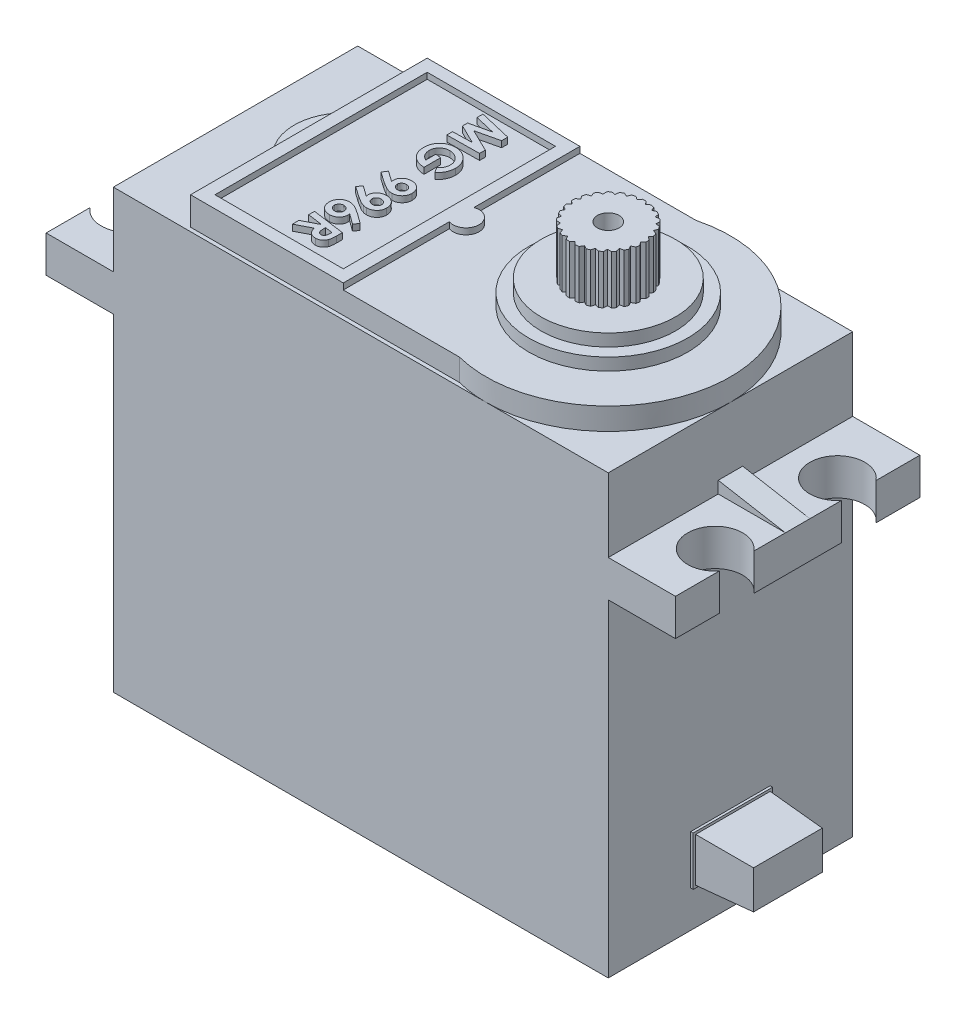
from build123d import *

# Parameters (mm, degrees)
ESQUISSE2_W             = 40.5
ESQUISSE2_H             = 20
BOSS_EXTRU_1_DEPTH      = 36.8
CHANFREIN1_SIZE         = 1
ESQUISSE3_W             = 6.5
ESQUISSE3_H             = 4
BOSS_EXTRU_2_DEPTH      = 0.2
ESQUISSE4_W             = 6.1
ESQUISSE4_H             = 3.6
BOSS_EXTRU_3_DEPTH      = 4.5
BOSS_EXTRU_3_TAPER      = 3
ESQUISSE5_W             = 5.5
ESQUISSE5_H             = 20
BOSS_EXTRU_4_DEPTH      = 3
BOSS_EXTRU_5_DEPTH      = 1.8
ESQUISSE8_W             = 12.5
ESQUISSE8_H             = 19.364916732
ESQUISSE8_W_2           = 10.5
ESQUISSE8_H_2           = 17.364916732
BOSS_EXTRU_6_DEPTH      = 0.5
NERVURE1_REACH          = 63.195
ESQUISSE6_WALL_W        = 129.97512572
ESQUISSE6_WALL_H        = 2
ESQUISSE9_R             = 2.25
ENL_V_MAT_EXTRU_1_DEPTH = 3
ESQUISSE10_R            = 1.069362743
BOSS_EXTRU_7_DEPTH      = 0.5
ESQUISSE11_R            = 6.5
BOSS_EXTRU_8_DEPTH      = 1
ESQUISSE12_R            = 5.5
BOSS_EXTRU_9_DEPTH      = 1
ESQUISSE13_R            = 3
BOSS_EXTRU_10_DEPTH     = 4
ENL_V_MAT_EXTRU_2_DEPTH = 4
TROU_TARAUD_2_561_D     = 1.778
TROU_TARAUD_2_561_DEPTH = 6.64
TROU_TARAUD_2_561_TIP   = 0.53416509
ENL_V_MAT_EXTRU_3_DEPTH = 0.5


with BuildPart() as part:
    # Esquisse2 → Boss.-Extru.1 (new body)
    with BuildSketch(Plane(origin=(0, 0, 0), x_dir=(1, 0, 0), z_dir=(0, 1, 0))):
        with Locations((20.25, 10)):
            Rectangle(ESQUISSE2_W, ESQUISSE2_H)
    extrude(amount=BOSS_EXTRU_1_DEPTH)

    # Chanfrein1
    chanfrein1_edges = [part.edges().sort_by_distance(p)[0] for p in [
        (20.25, 0, -20),
        (40.5, 0, -10),
        (20.25, 0, 0),
        (0, 0, -10),
    ]]
    chamfer(chanfrein1_edges, length=CHANFREIN1_SIZE)

    # Esquisse3 → Boss.-Extru.2 (add)
    with BuildSketch(Plane(origin=(40.5, 0, 0), x_dir=(0, 0, -1), z_dir=(1, 0, 0))):
        with Locations((10, 6)):
            Rectangle(ESQUISSE3_W, ESQUISSE3_H)
    extrude(amount=BOSS_EXTRU_2_DEPTH)

    # Esquisse4 → Boss.-Extru.3 (add)
    with BuildSketch(Plane(origin=(40.7, 0, 0), x_dir=(0, 0, -1), z_dir=(1, 0, 0))):
        with Locations((10, 6)):
            Rectangle(ESQUISSE4_W, ESQUISSE4_H)
    extrude(amount=BOSS_EXTRU_3_DEPTH, taper=BOSS_EXTRU_3_TAPER)

    # Esquisse5 → Boss.-Extru.4 (add)
    with BuildSketch(Plane(origin=(0, 30.8, 0), x_dir=(1, 0, 0), z_dir=(0, 1, 0))):
        with Locations((43.25, 10)):
            Rectangle(ESQUISSE5_W, ESQUISSE5_H)
        with Locations((-2.75, 10)):
            Rectangle(ESQUISSE5_W, ESQUISSE5_H)
    extrude(amount=-BOSS_EXTRU_4_DEPTH)

    # Esquisse7 → Boss.-Extru.5 (add)
    with BuildSketch(Plane(origin=(0, 36.8, 0), x_dir=(1, 0, 0), z_dir=(0, 1, 0))):
        with BuildLine():
            Line((28, 19.682458366), (6, 19.682458366))
            Line((6, 19.682458366), (6, 12.939387691))
            ThreePointArc((6, 12.939387691), (4.8, 10), (6, 7.060612309))
            Line((6, 7.060612309), (6, 0.317541634))
            Line((6, 0.317541634), (28, 0.317541634))
            ThreePointArc((28, 0.317541634), (40.5, 10), (28, 19.682458366))
        make_face()
    extrude(amount=BOSS_EXTRU_5_DEPTH)

    # Esquisse8 → Boss.-Extru.6 (add)
    with BuildSketch(Plane(origin=(0, 38.6, 0), x_dir=(1, 0, 0), z_dir=(0, 1, 0))):
        with Locations((12.25, 10)):
            Rectangle(ESQUISSE8_W, ESQUISSE8_H)
        with Locations((12.25, 10)):
            Rectangle(ESQUISSE8_W_2, ESQUISSE8_H_2, mode=Mode.SUBTRACT)
    extrude(amount=BOSS_EXTRU_6_DEPTH)

    # Esquisse6 wall → Nervure1 (add, up to next)
    with BuildSketch(Plane(origin=(43.25, 31.28654897, -10), x_dir=(-0.98470656344, 0.17422107771, 0), z_dir=(0.17422107771, 0.98470656344, 0)), mode=Mode.PRIVATE) as nervure1_sk1:
        Rectangle(ESQUISSE6_WALL_W, ESQUISSE6_WALL_H)
    nervure1_tool1 = extrude(nervure1_sk1.sketch, amount=-NERVURE1_REACH, mode=Mode.PRIVATE) - part.part
    nervure1 = nervure1_tool1.solids().sort_by_distance((43.25, 31.28654897, -10))[0]
    add(nervure1)

    # Symétrie1: Nervure1 across plane
    add(nervure1.mirror(Plane.ZY.offset(-20.25)))

    # Esquisse9 → Enlèv. mat.-Extru.1 (cut)
    with BuildSketch(Plane(origin=(0, 30.8, 0), x_dir=(1, 0, 0), z_dir=(0, 1, 0))):
        with Locations((-3.75, 15)):
            Circle(ESQUISSE9_R)
        with Locations((-3.75, 5)):
            Circle(ESQUISSE9_R)
        with Locations((44.25, 15)):
            Circle(ESQUISSE9_R)
        with Locations((44.25, 5)):
            Circle(ESQUISSE9_R)
    extrude(amount=-ENL_V_MAT_EXTRU_1_DEPTH, mode=Mode.SUBTRACT)

    # Esquisse10 → Boss.-Extru.7 (add)
    with BuildSketch(Plane(origin=(0, 38.6, 0), x_dir=(1, 0, 0), z_dir=(0, 1, 0))):
        with Locations((18.863979038, 10)):
            Circle(ESQUISSE10_R)
        Polygon((14.895833333, 17.378864517), (14.895833333, 16.873760517), (13.052442241, 16.444978632), (14.895833333, 15.539713542), (14.895833333, 15.071180556), (12.25, 15.037259615), (12.25, 15.512152778), (13.832623865, 15.546073718), (12.25, 16.323075254), (12.25, 16.737016727), (13.912126068, 17.123397436), (12.25, 17.514018263), (12.25, 18.000571748), align=None)
        with BuildLine():
            Line((14.413519965, 11.893212473), (14.14957265, 12.314574152))
            add(Edge.make_bspline(
                [(14.14957265, 12.314574152), (14.182226607, 12.344452028), (14.244607538, 12.401529634), (14.325928731, 12.491063998), (14.391922335, 12.578848082), (14.441898984, 12.667154377), (14.478787705, 12.757700404), (14.503895804, 12.852666333), (14.519754731, 12.95306459), (14.521705169, 13.021906131), (14.522702991, 13.057124733)],
                knots=[0, 0, 0, 0, 1.232885797, 2.355260147, 3.365556625, 4.287066597, 5.174814994, 6.082477048, 7.019015608, 8, 8, 8, 8], degree=3))
            add(Edge.make_bspline(
                [(14.522702991, 13.057124733), (14.521686925, 13.095364384), (14.519689994, 13.170518887), (14.500873636, 13.280150935), (14.471871138, 13.384693694), (14.430547824, 13.483730957), (14.37602753, 13.576738756), (14.310603553, 13.664500855), (14.233259477, 13.746911503), (14.174343486, 13.795530523), (14.144272503, 13.820345887)],
                knots=[0, 0, 0, 0, 1.037071857, 2.038214738, 3.009729149, 3.976855325, 4.941565424, 5.928389831, 6.942640983, 8, 8, 8, 8], degree=3))
            add(Edge.make_bspline(
                [(14.144272503, 13.820345887), (14.119098074, 13.838925772), (14.069293607, 13.875683755), (13.990748516, 13.923561019), (13.909783045, 13.96314346), (13.827256952, 13.9966325), (13.742303924, 14.021687181), (13.655425835, 14.040764914), (13.566285141, 14.051240002), (13.506159608, 14.052778618), (13.475923978, 14.05355235)],
                knots=[0, 0, 0, 0, 1.040839251, 2.059170575, 3.055630366, 4.037062373, 5.019110465, 5.999220985, 6.993858158, 8, 8, 8, 8], degree=3))
            add(Edge.make_bspline(
                [(13.475923978, 14.05355235), (13.446389285, 14.052838649), (13.388165025, 14.051431667), (13.302693434, 14.040347229), (13.221068283, 14.020814449), (13.142669436, 13.995202178), (13.068207437, 13.960903979), (12.997347209, 13.919389191), (12.930280706, 13.870317718), (12.86756691, 13.81430086), (12.810308914, 13.753008656), (12.76012294, 13.687570953), (12.717880889, 13.618626076), (12.683290563, 13.546146381), (12.656064777, 13.470176978), (12.637183746, 13.390531597), (12.625034783, 13.307666938), (12.623771226, 13.251153353), (12.623130342, 13.222489316)],
                knots=[0, 0, 0, 0, 1.066897471, 2.103265977, 3.106535126, 4.095591644, 5.078159493, 6.062322472, 7.058152725, 8.075375883, 9.096057735, 10.084186963, 11.049730852, 12.011871914, 12.980953841, 13.959387168, 14.96498868, 16, 16, 16, 16], degree=3))
            add(Edge.make_bspline(
                [(12.623130342, 13.222489316), (12.62352997, 13.200919765), (12.624321167, 13.158215716), (12.630867198, 13.094984655), (12.641499585, 13.033188568), (12.656192684, 12.972909638), (12.675512208, 12.914154242), (12.698930203, 12.856798498), (12.726293103, 12.80068424), (12.758406832, 12.746436633), (12.794238655, 12.693968773), (12.834685352, 12.644022395), (12.879496236, 12.596709454), (12.928435307, 12.551650676), (12.98124162, 12.508551759), (13.039018432, 12.46894969), (13.100490782, 12.431075996), (13.143816269, 12.408311625), (13.165865385, 12.396726429)],
                knots=[0, 0, 0, 0, 0.990751711, 1.961520103, 2.916931976, 3.869720035, 4.809138875, 5.755683625, 6.713987145, 7.674487982, 8.649319602, 9.630449541, 10.623757948, 11.640402946, 12.684918653, 13.752145235, 14.856026455, 16, 16, 16, 16], degree=3))
            Line((13.165865385, 12.396726429), (13.165865385, 13.232029581))
            Line((13.165865385, 13.232029581), (13.606837607, 13.171607906))
            Line((13.606837607, 13.171607906), (13.606837607, 11.814770299))
            add(Edge.make_bspline(
                [(13.606837607, 11.814770299), (13.553576953, 11.818164211), (13.449423544, 11.824801144), (13.297763777, 11.848819667), (13.154737828, 11.884392058), (13.019794624, 11.930502134), (12.893185857, 11.987615425), (12.775254695, 12.056619555), (12.665557739, 12.136162474), (12.565533037, 12.226966773), (12.475782242, 12.326397844), (12.396489875, 12.432596793), (12.330718138, 12.54636996), (12.276386727, 12.666200695), (12.233654404, 12.792560622), (12.203696237, 12.925771009), (12.185230178, 13.065613979), (12.183194733, 13.161126321), (12.18215812, 13.209768964)],
                knots=[0, 0, 0, 0, 1.148955532, 2.246830018, 3.301660101, 4.319666133, 5.314146826, 6.287838685, 7.257462643, 8.227280698, 9.191724348, 10.138440807, 11.076252923, 12.016254752, 12.968042649, 13.943717582, 14.952773983, 16, 16, 16, 16], degree=3))
            add(Edge.make_bspline(
                [(12.18215812, 13.209768964), (12.182422747, 13.236454621), (12.182945535, 13.289173934), (12.188315617, 13.367019666), (12.197484811, 13.442677664), (12.209525355, 13.516102052), (12.224926848, 13.587610509), (12.243849953, 13.656857329), (12.266805344, 13.724078008), (12.293385572, 13.788833866), (12.322306691, 13.852052819), (12.356049468, 13.912245692), (12.392500992, 13.970865644), (12.432978605, 14.026931448), (12.476454014, 14.081266613), (12.523609892, 14.133053839), (12.574262899, 14.1827447), (12.610237054, 14.213807595), (12.628430489, 14.229517228)],
                knots=[0, 0, 0, 0, 1.111489437, 2.195822267, 3.24832009, 4.285186852, 5.294177098, 6.294000398, 7.273796753, 8.250936178, 9.209044775, 10.167605497, 11.123223585, 12.083111191, 13.046265838, 14.020518746, 14.998904505, 16, 16, 16, 16], degree=3))
            add(Edge.make_bspline(
                [(12.628430489, 14.229517228), (12.658588763, 14.253396792), (12.718466815, 14.300808715), (12.814947345, 14.361673055), (12.915566575, 14.413613317), (13.020838592, 14.455207788), (13.12995092, 14.488460722), (13.243503183, 14.511673433), (13.361266447, 14.525638713), (13.441258231, 14.527502148), (13.48175414, 14.528445513)],
                knots=[0, 0, 0, 0, 0.999328569, 1.984127054, 2.959716786, 3.938705326, 4.922250225, 5.921072174, 6.947541011, 8, 8, 8, 8], degree=3))
            add(Edge.make_bspline(
                [(13.48175414, 14.528445513), (13.53129847, 14.527173323), (13.629061566, 14.52466298), (13.77282981, 14.503175961), (13.911565339, 14.469386095), (14.045327899, 14.42159429), (14.173480699, 14.359024131), (14.296477058, 14.283156585), (14.414850664, 14.194334344), (14.525642072, 14.092177215), (14.628023605, 13.981364426), (14.717958358, 13.863705939), (14.793658228, 13.740327698), (14.856346862, 13.612238591), (14.904011351, 13.478215362), (14.938507887, 13.339436142), (14.959884545, 13.195238002), (14.962398803, 13.097302998), (14.963675214, 13.047584468)],
                knots=[0, 0, 0, 0, 1.022497491, 2.017637963, 2.994389496, 3.967079589, 4.944335062, 5.93346684, 6.946839843, 7.995112064, 9.040696054, 10.058471571, 11.04760335, 12.024858823, 12.997548916, 13.978718102, 14.973858573, 16, 16, 16, 16], degree=3))
            add(Edge.make_bspline(
                [(14.963675214, 13.047584468), (14.963073734, 13.010268263), (14.96187604, 12.935962555), (14.948764051, 12.825348338), (14.929734364, 12.715895027), (14.901241146, 12.608753554), (14.866779416, 12.50483789), (14.825069394, 12.405472052), (14.77709042, 12.311265198), (14.721760549, 12.221593179), (14.658650029, 12.135656527), (14.58655147, 12.051845362), (14.504433106, 11.970418038), (14.444260862, 11.919318362), (14.413519965, 11.893212473)],
                knots=[0, 0, 0, 0, 1.013985835, 2.019094276, 3.024340414, 4.032027573, 5.029903266, 5.998629461, 6.958804651, 7.901192451, 8.859925033, 9.854431412, 10.903868303, 12, 12, 12, 12], degree=3))
        make_face()
        with BuildLine():
            Line((12.18215812, 9.722272302), (12.428084936, 10.089572483))
            Line((12.428084936, 10.089572483), (13.292008881, 9.478465545))
            add(Edge.make_bspline(
                [(13.292008881, 9.478465545), (13.285044745, 9.507656953), (13.271936971, 9.562600513), (13.269003247, 9.618990213), (13.267628205, 9.645420172)],
                knots=[0, 0, 0, 0, 1.062596194, 2, 2, 2, 2], degree=3))
            add(Edge.make_bspline(
                [(13.267628205, 9.645420172), (13.268370326, 9.669484416), (13.269834611, 9.716965777), (13.280592147, 9.786868361), (13.298781282, 9.853969752), (13.323754696, 9.91858972), (13.356185706, 9.980380058), (13.396602665, 10.038934361), (13.443356714, 10.095229716), (13.496534781, 10.148553985), (13.555489352, 10.196736567), (13.618316863, 10.239579909), (13.684811225, 10.275591006), (13.754446078, 10.305488754), (13.827595228, 10.328505371), (13.904383904, 10.343920384), (13.984439422, 10.354607871), (14.039116571, 10.355643708), (14.066890358, 10.356169872)],
                knots=[0, 0, 0, 0, 0.970086177, 1.914085144, 2.843757081, 3.768448548, 4.702069427, 5.650466095, 6.631863717, 7.649361026, 8.681859104, 9.697409525, 10.711084413, 11.725960042, 12.748829391, 13.796646255, 14.880785151, 16, 16, 16, 16], degree=3))
            add(Edge.make_bspline(
                [(14.066890358, 10.356169872), (14.098197844, 10.355518936), (14.159801729, 10.354238085), (14.250317834, 10.342276224), (14.336868289, 10.322673607), (14.419579012, 10.2957472), (14.497774244, 10.260469755), (14.572078653, 10.217814045), (14.642299223, 10.16708307), (14.708049837, 10.109288105), (14.76770795, 10.045249169), (14.820616324, 9.976906928), (14.864955402, 9.903596822), (14.900928581, 9.826020649), (14.929315065, 9.744194602), (14.949369106, 9.658239669), (14.961103379, 9.567831814), (14.962805317, 9.506237563), (14.963675214, 9.474755442)],
                knots=[0, 0, 0, 0, 1.067153374, 2.099842657, 3.106801845, 4.089832761, 5.060584944, 6.026765153, 7.006523203, 8.009636506, 9.007035051, 9.986663441, 10.951659663, 11.921944397, 12.897414564, 13.899858298, 14.926573288, 16, 16, 16, 16], degree=3))
            add(Edge.make_bspline(
                [(14.963675214, 9.474755442), (14.963051152, 9.446088804), (14.961824572, 9.389745137), (14.949549956, 9.307470148), (14.931272291, 9.228678737), (14.904666719, 9.153625098), (14.86994262, 9.082315393), (14.827840697, 9.014643187), (14.778218026, 8.950774394), (14.721695011, 8.891211855), (14.659741804, 8.837106924), (14.593764232, 8.789645513), (14.524432178, 8.749486789), (14.451309401, 8.717100659), (14.374775546, 8.691728494), (14.295030193, 8.672898961), (14.211692758, 8.66233727), (14.155078169, 8.660869964), (14.126252003, 8.660122863)],
                knots=[0, 0, 0, 0, 1.054249505, 2.072105013, 3.054563783, 4.027228313, 4.995537151, 5.967962625, 6.955035867, 7.966830736, 8.985184481, 9.977553814, 10.953342403, 11.928372592, 12.915253103, 13.916696589, 14.939254872, 16, 16, 16, 16], degree=3))
            add(Edge.make_bspline(
                [(14.126252003, 8.660122863), (14.102914166, 8.660489033), (14.056488057, 8.661217456), (13.987588394, 8.668329291), (13.919779494, 8.679961529), (13.875492157, 8.691107359), (13.853294438, 8.696693877)],
                knots=[0, 0, 0, 0, 1.013662365, 2.016484985, 3.005821674, 4, 4, 4, 4], degree=3))
            add(Edge.make_bspline(
                [(13.853294438, 8.696693877), (13.821887718, 8.706370116), (13.759147027, 8.725700181), (13.667547042, 8.761743499), (13.577671496, 8.801709608), (13.519749284, 8.832393511), (13.49076439, 8.847748064)],
                knots=[0, 0, 0, 0, 1.00191864, 2.001516544, 2.999937518, 4, 4, 4, 4], degree=3))
            add(Edge.make_bspline(
                [(13.49076439, 8.847748064), (13.441653178, 8.874830127), (13.345151324, 8.928045457), (13.205430961, 9.011901855), (13.071945365, 9.095963773), (12.986700987, 9.154861062), (12.944849259, 9.183777377)],
                knots=[0, 0, 0, 0, 1.049210121, 2.061662041, 3.048350216, 4, 4, 4, 4], degree=3))
            Line((12.944849259, 9.183777377), (12.18215812, 9.722272302))
        make_face()
        with BuildLine():
            add(Edge.make_bspline(
                [(13.708600427, 9.524576823), (13.709035217, 9.511479633), (13.709897329, 9.485510159), (13.715941075, 9.447349734), (13.725212391, 9.410397192), (13.739586639, 9.375402111), (13.75610301, 9.340901898), (13.778364906, 9.308978323), (13.803206007, 9.277666857), (13.832488349, 9.249102596), (13.863528526, 9.222008653), (13.897627985, 9.199422824), (13.932225857, 9.178769487), (13.969324504, 9.163200063), (14.007258901, 9.150034634), (14.047232721, 9.14207625), (14.088234294, 9.135580956), (14.116330443, 9.135205348), (14.130492121, 9.135016026)],
                knots=[0, 0, 0, 0, 0.985210318, 1.953502403, 2.901504212, 3.844552657, 4.795811415, 5.772915833, 6.765364857, 7.799414466, 8.846288802, 9.8603182, 10.872777757, 11.873031683, 12.88199396, 13.888500911, 14.935712839, 16, 16, 16, 16], degree=3))
            add(Edge.make_bspline(
                [(14.130492121, 9.135016026), (14.157143961, 9.13604922), (14.209147112, 9.138065192), (14.283241468, 9.159330417), (14.351318483, 9.191840168), (14.400879842, 9.230569974), (14.435944253, 9.266404387), (14.459417419, 9.294714951), (14.478648472, 9.325214323), (14.495268824, 9.356524442), (14.507446426, 9.390138865), (14.51644421, 9.424897614), (14.521948085, 9.461330131), (14.522448573, 9.486043361), (14.522702991, 9.498606103)],
                knots=[0, 0, 0, 0, 1.605710682, 3.133067493, 4.617246605, 6.139001981, 6.901113253, 7.644390981, 8.354770773, 9.075414747, 9.781050313, 10.508300066, 11.241708108, 12, 12, 12, 12], degree=3))
            add(Edge.make_bspline(
                [(14.522702991, 9.498606103), (14.522269913, 9.511877837), (14.521416852, 9.53801998), (14.515432771, 9.576394246), (14.505848066, 9.613140623), (14.492811368, 9.648395673), (14.474739767, 9.681484135), (14.453796485, 9.713340538), (14.428323669, 9.74334752), (14.399563232, 9.771525131), (14.368061273, 9.797369413), (14.334280593, 9.819814185), (14.298862501, 9.838986534), (14.261454941, 9.854239777), (14.222551458, 9.86677054), (14.181632759, 9.874880111), (14.138956083, 9.880581667), (14.109841649, 9.881041833), (14.094981136, 9.881276709)],
                knots=[0, 0, 0, 0, 0.99542305, 1.960745347, 2.905839599, 3.841219243, 4.772081027, 5.727802437, 6.696757192, 7.718306701, 8.745001724, 9.748509204, 10.756557466, 11.760764865, 12.775153388, 13.817469606, 14.885998626, 16, 16, 16, 16], degree=3))
            add(Edge.make_bspline(
                [(14.094981136, 9.881276709), (14.068706262, 9.880141045), (14.017537033, 9.877929387), (13.944133473, 9.858128398), (13.877187411, 9.826087871), (13.828333169, 9.788589095), (13.793554419, 9.754137239), (13.770977448, 9.726130977), (13.751346378, 9.69670676), (13.736291493, 9.665301665), (13.723777186, 9.632565508), (13.714818203, 9.598112565), (13.709359371, 9.561853625), (13.708856206, 9.537139845), (13.708600427, 9.524576823)],
                knots=[0, 0, 0, 0, 1.609136234, 3.133726194, 4.626556867, 6.135078296, 6.886042596, 7.625661421, 8.33802277, 9.050466543, 9.75695111, 10.485047691, 11.229887978, 12, 12, 12, 12], degree=3))
        make_face(mode=Mode.SUBTRACT)
        with BuildLine():
            Line((12.18215812, 7.653094952), (12.428084936, 8.020395132))
            Line((12.428084936, 8.020395132), (13.292008881, 7.409288194))
            add(Edge.make_bspline(
                [(13.292008881, 7.409288194), (13.285044745, 7.438479603), (13.271936971, 7.493423162), (13.269003247, 7.549812862), (13.267628205, 7.576242822)],
                knots=[0, 0, 0, 0, 1.062596194, 2, 2, 2, 2], degree=3))
            add(Edge.make_bspline(
                [(13.267628205, 7.576242822), (13.268370326, 7.600307066), (13.269834611, 7.647788427), (13.280592147, 7.717691011), (13.298781282, 7.784792402), (13.323754696, 7.84941237), (13.356185706, 7.911202708), (13.396602665, 7.96975701), (13.443356714, 8.026052366), (13.496534781, 8.079376634), (13.555489352, 8.127559217), (13.618316863, 8.170402559), (13.684811225, 8.206413656), (13.754446078, 8.236311403), (13.827595228, 8.259328021), (13.904383904, 8.274743034), (13.984439422, 8.285430521), (14.039116571, 8.286466358), (14.066890358, 8.286992521)],
                knots=[0, 0, 0, 0, 0.970086177, 1.914085144, 2.843757081, 3.768448548, 4.702069427, 5.650466095, 6.631863717, 7.649361026, 8.681859104, 9.697409525, 10.711084413, 11.725960042, 12.748829391, 13.796646255, 14.880785151, 16, 16, 16, 16], degree=3))
            add(Edge.make_bspline(
                [(14.066890358, 8.286992521), (14.098197844, 8.286341585), (14.159801729, 8.285060735), (14.250317834, 8.273098874), (14.336868289, 8.253496257), (14.419579012, 8.22656985), (14.497774244, 8.191292404), (14.572078653, 8.148636695), (14.642299223, 8.09790572), (14.708049837, 8.040110754), (14.76770795, 7.976071819), (14.820616324, 7.907729577), (14.864955402, 7.834419472), (14.900928581, 7.756843298), (14.929315065, 7.675017251), (14.949369106, 7.589062318), (14.961103379, 7.498654464), (14.962805317, 7.437060212), (14.963675214, 7.405578092)],
                knots=[0, 0, 0, 0, 1.067153374, 2.099842657, 3.106801845, 4.089832761, 5.060584944, 6.026765153, 7.006523203, 8.009636506, 9.007035051, 9.986663441, 10.951659663, 11.921944397, 12.897414564, 13.899858298, 14.926573288, 16, 16, 16, 16], degree=3))
            add(Edge.make_bspline(
                [(14.963675214, 7.405578092), (14.963051152, 7.376911454), (14.961824572, 7.320567786), (14.949549956, 7.238292797), (14.931272291, 7.159501386), (14.904666719, 7.084447748), (14.86994262, 7.013138043), (14.827840697, 6.945465836), (14.778218026, 6.881597044), (14.721695011, 6.822034504), (14.659741804, 6.767929574), (14.593764232, 6.720468163), (14.524432178, 6.680309439), (14.451309401, 6.647923309), (14.374775546, 6.622551144), (14.295030193, 6.60372161), (14.211692758, 6.593159919), (14.155078169, 6.591692613), (14.126252003, 6.590945513)],
                knots=[0, 0, 0, 0, 1.054249505, 2.072105013, 3.054563783, 4.027228313, 4.995537151, 5.967962625, 6.955035867, 7.966830736, 8.985184481, 9.977553814, 10.953342403, 11.928372592, 12.915253103, 13.916696589, 14.939254872, 16, 16, 16, 16], degree=3))
            add(Edge.make_bspline(
                [(14.126252003, 6.590945513), (14.102914166, 6.591311682), (14.056488057, 6.592040106), (13.987588394, 6.59915194), (13.919779494, 6.610784179), (13.875492157, 6.621930009), (13.853294438, 6.627516526)],
                knots=[0, 0, 0, 0, 1.013662365, 2.016484985, 3.005821674, 4, 4, 4, 4], degree=3))
            add(Edge.make_bspline(
                [(13.853294438, 6.627516526), (13.821887718, 6.637192765), (13.759147027, 6.65652283), (13.667547042, 6.692566149), (13.577671496, 6.732532258), (13.519749284, 6.76321616), (13.49076439, 6.778570713)],
                knots=[0, 0, 0, 0, 1.00191864, 2.001516544, 2.999937518, 4, 4, 4, 4], degree=3))
            add(Edge.make_bspline(
                [(13.49076439, 6.778570713), (13.441653178, 6.805652777), (13.345151324, 6.858868107), (13.205430961, 6.942724505), (13.071945365, 7.026786422), (12.986700987, 7.085683711), (12.944849259, 7.114600027)],
                knots=[0, 0, 0, 0, 1.049210121, 2.061662041, 3.048350216, 4, 4, 4, 4], degree=3))
            Line((12.944849259, 7.114600027), (12.18215812, 7.653094952))
        make_face()
        with BuildLine():
            add(Edge.make_bspline(
                [(13.708600427, 7.455399472), (13.709035217, 7.442302282), (13.709897329, 7.416332809), (13.715941075, 7.378172383), (13.725212391, 7.341219842), (13.739586639, 7.30622476), (13.75610301, 7.271724548), (13.778364906, 7.239800973), (13.803206007, 7.208489506), (13.832488349, 7.179925245), (13.863528526, 7.152831302), (13.897627985, 7.130245474), (13.932225857, 7.109592136), (13.969324504, 7.094022712), (14.007258901, 7.080857283), (14.047232721, 7.0728989), (14.088234294, 7.066403606), (14.116330443, 7.066027998), (14.130492121, 7.065838675)],
                knots=[0, 0, 0, 0, 0.985210318, 1.953502403, 2.901504212, 3.844552657, 4.795811415, 5.772915833, 6.765364857, 7.799414466, 8.846288802, 9.8603182, 10.872777757, 11.873031683, 12.88199396, 13.888500911, 14.935712839, 16, 16, 16, 16], degree=3))
            add(Edge.make_bspline(
                [(14.130492121, 7.065838675), (14.157143961, 7.06687187), (14.209147112, 7.068887842), (14.283241468, 7.090153067), (14.351318483, 7.122662817), (14.400879842, 7.161392623), (14.435944253, 7.197227037), (14.459417419, 7.225537601), (14.478648472, 7.256036972), (14.495268824, 7.287347092), (14.507446426, 7.320961514), (14.51644421, 7.355720264), (14.521948085, 7.392152781), (14.522448573, 7.416866011), (14.522702991, 7.429428753)],
                knots=[0, 0, 0, 0, 1.605710682, 3.133067493, 4.617246605, 6.139001981, 6.901113253, 7.644390981, 8.354770773, 9.075414747, 9.781050313, 10.508300066, 11.241708108, 12, 12, 12, 12], degree=3))
            add(Edge.make_bspline(
                [(14.522702991, 7.429428753), (14.522269913, 7.442700487), (14.521416852, 7.468842629), (14.515432771, 7.507216895), (14.505848066, 7.543963272), (14.492811368, 7.579218323), (14.474739767, 7.612306785), (14.453796485, 7.644163187), (14.428323669, 7.67417017), (14.399563232, 7.702347781), (14.368061273, 7.728192063), (14.334280593, 7.750636835), (14.298862501, 7.769809184), (14.261454941, 7.785062426), (14.222551458, 7.79759319), (14.181632759, 7.80570276), (14.138956083, 7.811404317), (14.109841649, 7.811864483), (14.094981136, 7.812099359)],
                knots=[0, 0, 0, 0, 0.99542305, 1.960745347, 2.905839599, 3.841219243, 4.772081027, 5.727802437, 6.696757192, 7.718306701, 8.745001724, 9.748509204, 10.756557466, 11.760764865, 12.775153388, 13.817469606, 14.885998626, 16, 16, 16, 16], degree=3))
            add(Edge.make_bspline(
                [(14.094981136, 7.812099359), (14.068706262, 7.810963695), (14.017537033, 7.808752037), (13.944133473, 7.788951048), (13.877187411, 7.756910521), (13.828333169, 7.719411745), (13.793554419, 7.684959889), (13.770977448, 7.656953627), (13.751346378, 7.62752941), (13.736291493, 7.596124314), (13.723777186, 7.563388158), (13.714818203, 7.528935214), (13.709359371, 7.492676275), (13.708856206, 7.467962495), (13.708600427, 7.455399472)],
                knots=[0, 0, 0, 0, 1.609136234, 3.133726194, 4.626556867, 6.135078296, 6.886042596, 7.625661421, 8.33802277, 9.050466543, 9.75695111, 10.485047691, 11.229887978, 12, 12, 12, 12], degree=3))
        make_face(mode=Mode.SUBTRACT)
        with BuildLine():
            Line((14.963675214, 5.230397803), (14.715628339, 4.856207432))
            Line((14.715628339, 4.856207432), (13.851704394, 5.485864884))
            add(Edge.make_bspline(
                [(13.851704394, 5.485864884), (13.855777165, 5.470715729), (13.863728117, 5.441141223), (13.872191365, 5.397426144), (13.877192941, 5.355775866), (13.877874367, 5.328816242), (13.878205128, 5.315730168)],
                knots=[0, 0, 0, 0, 1.089609887, 2.127159907, 3.090932268, 4, 4, 4, 4], degree=3))
            add(Edge.make_bspline(
                [(13.878205128, 5.315730168), (13.877455949, 5.291139017), (13.875977463, 5.242609027), (13.865343356, 5.171263743), (13.846877066, 5.102859399), (13.822428086, 5.036669894), (13.788610828, 4.97408479), (13.749721534, 4.913170376), (13.702436464, 4.855723128), (13.648843314, 4.801832949), (13.590345582, 4.752077921), (13.527647789, 4.708348257), (13.461160341, 4.671691674), (13.391289018, 4.641967567), (13.318202403, 4.618497671), (13.241588402, 4.601540225), (13.161376791, 4.591258551), (13.106710995, 4.590165347), (13.078942975, 4.589610043)],
                knots=[0, 0, 0, 0, 0.981715411, 1.937389526, 2.871580341, 3.806968751, 4.747211669, 5.7059007, 6.688578603, 7.711082162, 8.737083298, 9.750667409, 10.757800367, 11.76273248, 12.777714656, 13.818234204, 14.891750959, 16, 16, 16, 16], degree=3))
            add(Edge.make_bspline(
                [(13.078942975, 4.589610043), (13.047626205, 4.590195647), (12.985980854, 4.591348377), (12.89557458, 4.604250308), (12.808859798, 4.623457814), (12.726242983, 4.65115616), (12.64780308, 4.686971739), (12.573278252, 4.730507867), (12.503005379, 4.782469313), (12.437061226, 4.841306691), (12.37770705, 4.906732716), (12.325075182, 4.976555907), (12.280857948, 5.05122745), (12.244894792, 5.130388417), (12.216523098, 5.213799613), (12.19640816, 5.301504048), (12.18476632, 5.393682475), (12.183038507, 5.456504628), (12.18215812, 5.488514957)],
                knots=[0, 0, 0, 0, 1.056630681, 2.079919763, 3.076949805, 4.052168332, 5.015806961, 5.983608992, 6.960722918, 7.961866351, 8.962583205, 9.938458249, 10.909288654, 11.886256911, 12.869035103, 13.879024606, 14.919280581, 16, 16, 16, 16], degree=3))
            add(Edge.make_bspline(
                [(12.18215812, 5.488514957), (12.182771049, 5.517714457), (12.183976035, 5.575119069), (12.196441717, 5.659095322), (12.214148245, 5.739717696), (12.242126788, 5.815827984), (12.275525659, 5.888955989), (12.318217242, 5.957628308), (12.367378299, 6.023050074), (12.424135297, 6.083684711), (12.486083392, 6.13881837), (12.551885588, 6.187452832), (12.621634459, 6.228108402), (12.694643851, 6.261373485), (12.771104938, 6.287696008), (12.850864632, 6.306044721), (12.934089361, 6.317560317), (12.990745655, 6.318897448), (13.01958133, 6.319577991)],
                knots=[0, 0, 0, 0, 1.063306671, 2.090402461, 3.088389398, 4.065895744, 5.03947144, 6.013408992, 7.006231883, 8.017587523, 9.034563496, 10.024857058, 10.99440066, 11.971122141, 12.944378439, 13.936094236, 14.949558597, 16, 16, 16, 16], degree=3))
            add(Edge.make_bspline(
                [(13.01958133, 6.319577991), (13.042921851, 6.31922767), (13.089353298, 6.318530775), (13.158184079, 6.311188599), (13.226112298, 6.300438346), (13.270351147, 6.289182366), (13.292538896, 6.283536993)],
                knots=[0, 0, 0, 0, 1.013987145, 2.017131071, 3.005503137, 4, 4, 4, 4], degree=3))
            add(Edge.make_bspline(
                [(13.292538896, 6.283536993), (13.323741277, 6.27396831), (13.386165242, 6.254825055), (13.477876365, 6.220248987), (13.56771698, 6.180480445), (13.625891585, 6.150279902), (13.655068944, 6.135132879)],
                knots=[0, 0, 0, 0, 0.997754642, 1.996123332, 2.994959615, 4, 4, 4, 4], degree=3))
            add(Edge.make_bspline(
                [(13.655068944, 6.135132879), (13.703827728, 6.107158063), (13.800005377, 6.051977194), (13.939086413, 5.965412379), (14.072132307, 5.878190813), (14.157013742, 5.817410571), (14.198864016, 5.787443243)],
                knots=[0, 0, 0, 0, 1.04448181, 2.060260654, 3.043623333, 4, 4, 4, 4], degree=3))
            Line((14.198864016, 5.787443243), (14.963675214, 5.230397803))
        make_face()
        with BuildLine():
            add(Edge.make_bspline(
                [(13.437232906, 5.437633547), (13.436800045, 5.451434787), (13.435947071, 5.478630819), (13.429954723, 5.518581158), (13.420409402, 5.556929174), (13.407202354, 5.593838969), (13.389410621, 5.629130592), (13.367751512, 5.662747185), (13.342441058, 5.695098557), (13.313604986, 5.725345762), (13.282102347, 5.753269959), (13.248587085, 5.777810826), (13.213429223, 5.798541322), (13.176806514, 5.815803263), (13.138216484, 5.828216426), (13.09845392, 5.838152798), (13.056809854, 5.843205154), (13.028602226, 5.844186565), (13.014281183, 5.844684829)],
                knots=[0, 0, 0, 0, 1.015142161, 2.000388339, 2.965014229, 3.918897259, 4.877990632, 5.865890964, 6.856523611, 7.895434724, 8.935970661, 9.949863928, 10.946277865, 11.934861984, 12.921307697, 13.923806661, 14.945914428, 16, 16, 16, 16], degree=3))
            add(Edge.make_bspline(
                [(13.014281183, 5.844684829), (12.98779433, 5.843489228), (12.936252333, 5.841162654), (12.862430662, 5.8191235), (12.794352194, 5.785274533), (12.74488899, 5.744647559), (12.709891678, 5.707431208), (12.686077542, 5.677915896), (12.667345484, 5.645770157), (12.651168385, 5.612719375), (12.638321984, 5.578154261), (12.629299107, 5.541723532), (12.623922996, 5.503695194), (12.623396199, 5.477755296), (12.623130342, 5.464664296)],
                knots=[0, 0, 0, 0, 1.56542767, 3.046238249, 4.525383395, 6.043922793, 6.806539608, 7.551940033, 8.284293461, 9.005189027, 9.730402505, 10.464026277, 11.224845398, 12, 12, 12, 12], degree=3))
            add(Edge.make_bspline(
                [(12.623130342, 5.464664296), (12.623572491, 5.450864019), (12.62444937, 5.423495036), (12.630363382, 5.383359745), (12.639854847, 5.344978881), (12.653274996, 5.308319377), (12.670890817, 5.273423786), (12.692024029, 5.239907127), (12.717307196, 5.20849364), (12.745720703, 5.178872477), (12.777262932, 5.152224463), (12.810816984, 5.128506361), (12.846588639, 5.10913274), (12.883578598, 5.092305852), (12.922855179, 5.080274821), (12.963629974, 5.071400455), (13.006137887, 5.065094183), (13.035105077, 5.064702034), (13.049792167, 5.064503205)],
                knots=[0, 0, 0, 0, 1.015070448, 2.013107881, 2.977665625, 3.919272353, 4.878297972, 5.848182152, 6.828546253, 7.839615093, 8.863054493, 9.861768677, 10.856500359, 11.851486719, 12.846218401, 13.871059717, 14.920574032, 16, 16, 16, 16], degree=3))
            add(Edge.make_bspline(
                [(13.049792167, 5.064503205), (13.07641759, 5.065812967), (13.127967408, 5.068348815), (13.20204201, 5.088489335), (13.268630047, 5.122594094), (13.317996132, 5.161039552), (13.352095649, 5.197511228), (13.375128792, 5.226578415), (13.39431451, 5.257776326), (13.41037241, 5.290306924), (13.421848319, 5.325042065), (13.43107649, 5.360911263), (13.436456031, 5.398780264), (13.436971168, 5.424543409), (13.437232906, 5.437633547)],
                knots=[0, 0, 0, 0, 1.593872869, 3.085917389, 4.558304015, 6.051287104, 6.807658976, 7.546719932, 8.269374006, 8.998512182, 9.714936363, 10.456948278, 11.215982398, 12, 12, 12, 12], degree=3))
        make_face(mode=Mode.SUBTRACT)
        with BuildLine():
            Line((14.895833333, 3.845469418), (14.895833333, 3.385946681))
            add(Edge.make_bspline(
                [(14.895833333, 3.385946681), (14.895693975, 3.351845127), (14.895425275, 3.286093229), (14.89160437, 3.191539862), (14.8858398, 3.104755957), (14.878232309, 3.025844703), (14.86767734, 2.954740219), (14.855003986, 2.891590369), (14.84089044, 2.835991802), (14.827775212, 2.802649538), (14.821631277, 2.787030081)],
                knots=[0, 0, 0, 0, 1.348808202, 2.600664361, 3.742342956, 4.788858012, 5.735658768, 6.584006912, 7.336666444, 8, 8, 8, 8], degree=3))
            add(Edge.make_bspline(
                [(14.821631277, 2.787030081), (14.813702006, 2.769443737), (14.798201536, 2.735065216), (14.771910784, 2.68581706), (14.743651829, 2.639645293), (14.711990082, 2.597461126), (14.679421641, 2.557675143), (14.643361729, 2.522304698), (14.606066345, 2.489206709), (14.565965316, 2.460053954), (14.524226078, 2.434061719), (14.480497095, 2.411574601), (14.434638487, 2.393082271), (14.386958222, 2.37781901), (14.337445205, 2.365350639), (14.285992945, 2.357232888), (14.232736116, 2.351535706), (14.196583165, 2.351066606), (14.178193443, 2.350827991)],
                knots=[0, 0, 0, 0, 1.116127165, 2.18185197, 3.228774211, 4.245094647, 5.232142401, 6.200910902, 7.164648772, 8.115556249, 9.066023899, 10.007984838, 10.95729697, 11.924067173, 12.903566711, 13.908717315, 14.936238762, 16, 16, 16, 16], degree=3))
            add(Edge.make_bspline(
                [(14.178193443, 2.350827991), (14.155563612, 2.351388707), (14.110888661, 2.352495649), (14.045006951, 2.359721062), (13.981796161, 2.373219443), (13.921012476, 2.391324865), (13.862501271, 2.413988847), (13.806592883, 2.442223961), (13.753326713, 2.475957451), (13.702394838, 2.514544894), (13.65471591, 2.558462532), (13.610835959, 2.607912176), (13.570640652, 2.662315299), (13.534635192, 2.722357482), (13.501468907, 2.786947886), (13.473312194, 2.857452749), (13.447344968, 2.93261348), (13.434346168, 2.985312148), (13.427692642, 3.012286325)],
                knots=[0, 0, 0, 0, 0.995319876, 1.964922578, 2.909737992, 3.8340754, 4.751759393, 5.665652718, 6.58399436, 7.521078272, 8.472357359, 9.429930406, 10.424522133, 11.442601115, 12.505929285, 13.614075567, 14.778748082, 16, 16, 16, 16], degree=3))
            Line((13.427692642, 3.012286325), (12.25, 2.401709402))
            Line((12.25, 2.401709402), (12.25, 2.932254107))
            Line((12.25, 2.932254107), (13.403311966, 3.530110677))
            Line((13.403311966, 3.530110677), (13.403311966, 3.575161926))
            Line((13.403311966, 3.575161926), (12.25, 3.737346421))
            Line((12.25, 3.737346421), (12.25, 4.216479701))
            Line((12.25, 4.216479701), (14.895833333, 3.845469418))
        make_face()
        with BuildLine():
            add(Edge.make_bspline(
                [(13.844284188, 3.513150207), (13.844600849, 3.479047627), (13.845206541, 3.413817972), (13.849419571, 3.320657129), (13.856074628, 3.236647541), (13.86558514, 3.162031492), (13.876832633, 3.096612701), (13.890874325, 3.040669071), (13.907569641, 2.993944181), (13.927368618, 2.955701062), (13.950614549, 2.924721501), (13.975421602, 2.89790736), (14.00319035, 2.875579764), (14.033454616, 2.857157496), (14.066277128, 2.842949007), (14.101880253, 2.832702491), (14.140026605, 2.82703711), (14.166338646, 2.826166179), (14.179783487, 2.825721154)],
                knots=[0, 0, 0, 0, 1.892208387, 3.619318591, 5.173427176, 6.566868293, 7.791773198, 8.8545744, 9.763297566, 10.539470204, 11.233547833, 11.906251103, 12.5615143, 13.203742025, 13.866659999, 14.539934446, 15.25394049, 16, 16, 16, 16], degree=3))
            add(Edge.make_bspline(
                [(14.179783487, 2.825721154), (14.195048239, 2.826220876), (14.224700139, 2.827191591), (14.266985198, 2.837911403), (14.305936466, 2.853467803), (14.34034043, 2.876853327), (14.370021351, 2.906312585), (14.395680708, 2.941312768), (14.414625863, 2.982841097), (14.427980656, 3.021385485), (14.435383964, 3.057901173), (14.440443653, 3.092059591), (14.445339602, 3.132687908), (14.448859102, 3.179552043), (14.451311744, 3.232757699), (14.453594812, 3.292116602), (14.454424509, 3.357853902), (14.454711172, 3.403790597), (14.454861111, 3.427817842)],
                knots=[0, 0, 0, 0, 0.974566619, 1.893103166, 2.774869034, 3.646503934, 4.533832137, 5.440606451, 6.40634732, 7.443055867, 8.043908415, 8.787358366, 9.65251809, 10.661742722, 11.793623988, 13.060556557, 14.462520515, 16, 16, 16, 16], degree=3))
            Line((14.454861111, 3.427817842), (13.844284188, 3.513150207))
        make_face(mode=Mode.SUBTRACT)
    extrude(amount=BOSS_EXTRU_7_DEPTH)

    # Esquisse11 → Boss.-Extru.8 (add)
    with BuildSketch(Plane(origin=(0, 38.6, 0), x_dir=(1, 0, 0), z_dir=(0, 1, 0))):
        with Locations(Location((30.5, 10, 0), (0, 0, 270))):
            Circle(ESQUISSE11_R)
    extrude(amount=BOSS_EXTRU_8_DEPTH)

    # Esquisse12 → Boss.-Extru.9 (add)
    with BuildSketch(Plane(origin=(0, 39.6, 0), x_dir=(1, 0, 0), z_dir=(0, 1, 0))):
        with Locations(Location((30.5, 10, 0), (0, 0, 270))):
            Circle(ESQUISSE12_R)
    extrude(amount=BOSS_EXTRU_9_DEPTH)

    # Esquisse13 → Boss.-Extru.10 (add)
    with BuildSketch(Plane(origin=(0, 40.6, 0), x_dir=(1, 0, 0), z_dir=(0, 1, 0))):
        with Locations(Location((30.5, 10, 0), (0, 0, 270))):
            Circle(ESQUISSE13_R)
    extrude(amount=BOSS_EXTRU_10_DEPTH)

    # Esquisse14 → Enlèv. mat.-Extru.2 (cut)
    with BuildSketch(Plane(origin=(0, 44.6, 0), x_dir=(1, 0, 0), z_dir=(0, 1, 0))):
        with BuildLine():
            ThreePointArc((27.872197438, 8.552708152), (27.9908144, 8.355619379), (28.124183692, 8.168198463))
            Line((28.124183692, 8.168198463), (28.194050686, 8.480765427))
            Line((28.194050686, 8.480765427), (27.872197438, 8.552708152))
        make_face()
        with BuildLine():
            ThreePointArc((28.314681534, 7.944669564), (28.478585911, 7.783271537), (28.654374848, 7.634906387))
            Line((28.654374848, 7.634906387), (28.644314599, 7.9550287))
            Line((28.644314599, 7.9550287), (28.314681534, 7.944669564))
        make_face()
        with BuildLine():
            ThreePointArc((28.894477226, 7.465774946), (29.093370303, 7.350208896), (29.300533419, 7.250221841))
            Line((29.300533419, 7.250221841), (29.21117805, 7.557785041))
            Line((29.21117805, 7.557785041), (28.894477226, 7.465774946))
        make_face()
        with BuildLine():
            ThreePointArc((29.575153819, 7.146115009), (29.796538412, 7.083642375), (30.022058888, 7.03831597))
            Line((30.022058888, 7.03831597), (29.859022924, 7.313994729))
            Line((29.859022924, 7.313994729), (29.575153819, 7.146115009))
        make_face()
        with BuildLine():
            Line((30.547142745, 7.238976007), (30.313941899, 7.005775162))
            ThreePointArc((30.313941899, 7.005775162), (30.5439076, 7.00032133), (30.773615154, 7.012503599))
            Line((30.773615154, 7.012503599), (30.547142745, 7.238976007))
        make_face()
        with BuildLine():
            Line((31.232300414, 7.337442577), (31.064420694, 7.053573473))
            ThreePointArc((31.064420694, 7.053573473), (31.288517912, 7.105481128), (31.507979174, 7.174406614))
            Line((31.507979174, 7.174406614), (31.232300414, 7.337442577))
        make_face()
        with BuildLine():
            Line((31.871444955, 7.603207422), (31.77943486, 7.286506599))
            ThreePointArc((31.77943486, 7.286506599), (31.983582744, 7.392514191), (32.179008155, 7.513852053))
            Line((32.179008155, 7.513852053), (31.871444955, 7.603207422))
        make_face()
        with BuildLine():
            Line((32.424416566, 8.01957156), (32.414057429, 7.689938495))
            ThreePointArc((32.414057429, 7.689938495), (32.585428615, 7.843385178), (32.744538879, 8.009511311))
            Line((32.744538879, 8.009511311), (32.424416566, 8.01957156))
        make_face()
        with BuildLine():
            Line((32.856470006, 8.560373299), (32.92841273, 8.238520051))
            ThreePointArc((32.92841273, 8.238520051), (33.056239337, 8.429764205), (33.16903697, 8.630240294))
            Line((33.16903697, 8.630240294), (32.856470006, 8.560373299))
        make_face()
        with BuildLine():
            ThreePointArc((27.594827841, 9.251685409), (27.660704249, 9.031289704), (27.743273813, 8.816589366))
            Line((27.743273813, 8.816589366), (27.88867805, 9.10196125))
            Line((27.88867805, 9.10196125), (27.594827841, 9.251685409))
        make_face()
        with BuildLine():
            ThreePointArc((27.500000896, 9.997682024), (27.508997492, 9.767827659), (27.535579178, 9.539338312))
            Line((27.535579178, 9.539338312), (27.747384375, 9.779584149))
            Line((27.747384375, 9.779584149), (27.500000896, 9.997682024))
        make_face()
        with BuildLine():
            ThreePointArc((27.593674927, 10.743824287), (27.545226422, 10.518953857), (27.514150006, 10.291032326))
            Line((27.514150006, 10.291032326), (27.779047664, 10.471056588))
            Line((27.779047664, 10.471056588), (27.593674927, 10.743824287))
        make_face()
        with BuildLine():
            ThreePointArc((27.869964051, 11.443229333), (27.767114644, 11.237472275), (27.680332771, 11.024439708))
            Line((27.680332771, 11.024439708), (27.981678394, 11.132930808))
            Line((27.981678394, 11.132930808), (27.869964051, 11.443229333))
        make_face()
        with BuildLine():
            ThreePointArc((28.890562963, 12.531740987), (28.701311122, 12.400982782), (28.522634365, 12.256108407))
            Line((28.522634365, 12.256108407), (28.838971534, 12.206005522))
            Line((28.838971534, 12.206005522), (28.890562963, 12.531740987))
        make_face()
        with BuildLine():
            ThreePointArc((28.311508007, 12.051950973), (28.160720103, 11.878235758), (28.023685597, 11.693477776))
            Line((28.023685597, 11.693477776), (28.342544533, 11.72361882))
            Line((28.342544533, 11.72361882), (28.311508007, 12.051950973))
        make_face()
        with BuildLine():
            ThreePointArc((29.570744768, 12.852452403), (29.354920377, 12.772867227), (29.145828287, 12.676979449))
            Line((29.145828287, 12.676979449), (29.439767062, 12.549780783))
            Line((29.439767062, 12.549780783), (29.570744768, 12.852452403))
        make_face()
        with BuildLine():
            ThreePointArc((30.309315096, 12.993933745), (30.080479197, 12.970522226), (29.854109799, 12.929646028))
            Line((29.854109799, 12.929646028), (30.107180925, 12.733343941))
            Line((30.107180925, 12.733343941), (30.309315096, 12.993933745))
        make_face()
        with BuildLine():
            ThreePointArc((31.059866858, 12.947295218), (30.832398052, 12.981528389), (30.602974968, 12.998232172))
            Line((30.602974968, 12.998232172), (30.799277054, 12.745161046))
            Line((30.799277054, 12.745161046), (31.059866858, 12.947295218))
        make_face()
        with BuildLine():
            Line((31.472568506, 12.584489587), (31.775240126, 12.715467293))
            ThreePointArc((31.775240126, 12.715467293), (31.563431114, 12.805194158), (31.34536984, 12.878428362))
            Line((31.34536984, 12.878428362), (31.472568506, 12.584489587))
        make_face()
        with BuildLine():
            Line((32.084749902, 12.261425142), (32.410485368, 12.313016572))
            ThreePointArc((32.410485368, 12.313016572), (32.227644889, 12.452599261), (32.034647017, 12.577762311))
            Line((32.034647017, 12.577762311), (32.084749902, 12.261425142))
        make_face()
        with BuildLine():
            Line((32.597355633, 11.796267039), (32.925687787, 11.765230512))
            ThreePointArc((32.925687787, 11.765230512), (32.783304382, 11.945898533), (32.627496677, 12.115125975))
            Line((32.627496677, 12.115125975), (32.597355633, 11.796267039))
        make_face()
        with BuildLine():
            Line((32.978176796, 11.218242871), (33.288475321, 11.106528528))
            ThreePointArc((33.288475321, 11.106528528), (33.195495462, 11.316929843), (33.086667897, 11.519588494))
            Line((33.086667897, 11.519588494), (32.978176796, 11.218242871))
        make_face()
        with BuildLine():
            Line((33.203284997, 10.563672023), (33.476052696, 10.378299286))
            ThreePointArc((33.476052696, 10.378299286), (33.43831865, 10.605213608), (33.383309259, 10.82856968))
            Line((33.383309259, 10.82856968), (33.203284997, 10.563672023))
        make_face()
        with BuildLine():
            Line((33.25853586, 9.873683589), (33.476633735, 9.626300109))
            ThreePointArc((33.476633735, 9.626300109), (33.494152735, 9.812785156), (33.5, 10))
            ThreePointArc((33.5, 10), (33.499695409, 10.042748733), (33.498781697, 10.085488786))
            Line((33.498781697, 10.085488786), (33.25853586, 9.873683589))
        make_face()
        with BuildLine():
            Line((33.140457769, 9.191632079), (33.290181929, 8.897781871))
            ThreePointArc((33.290181929, 8.897781871), (33.36643214, 9.114806923), (33.425829652, 9.337036316))
            Line((33.425829652, 9.337036316), (33.140457769, 9.191632079))
        make_face()
    extrude(amount=-ENL_V_MAT_EXTRU_2_DEPTH, mode=Mode.SUBTRACT)

    # Trou taraudé #2-561
    with Locations(Plane(origin=(0, 44.6, 0), x_dir=(1, 0, 0), z_dir=(0, 1, 0))):
        with Locations((30.5, 10)):
            Hole(TROU_TARAUD_2_561_D / 2, depth=TROU_TARAUD_2_561_DEPTH)
            with Locations((0, 0, -(TROU_TARAUD_2_561_DEPTH + TROU_TARAUD_2_561_TIP / 2))):  # 118° drill point
                Cone(0, TROU_TARAUD_2_561_D / 2, TROU_TARAUD_2_561_TIP, mode=Mode.SUBTRACT)

    # Esquisse17 → Enlèv. mat.-Extru.3 (cut)
    with BuildSketch(Plane.XZ):
        Polygon((10.130063774, -5.014715563), (18.211190013, -9.260234782), (15.445504393, -9.260234782), (12.133373724, -7.401969889), (13.268150987, -9.260234782), (11.645169492, -9.260234782), align=None)
        Polygon((11.645169492, -9.821415864), (10.130063774, -14.066935084), (18.211190013, -9.821415864), (15.445504393, -9.821415864), (12.133373724, -11.679680757), (13.268150987, -9.821415864), align=None)
    extrude(amount=-ENL_V_MAT_EXTRU_3_DEPTH, mode=Mode.SUBTRACT)


solid = part.part
